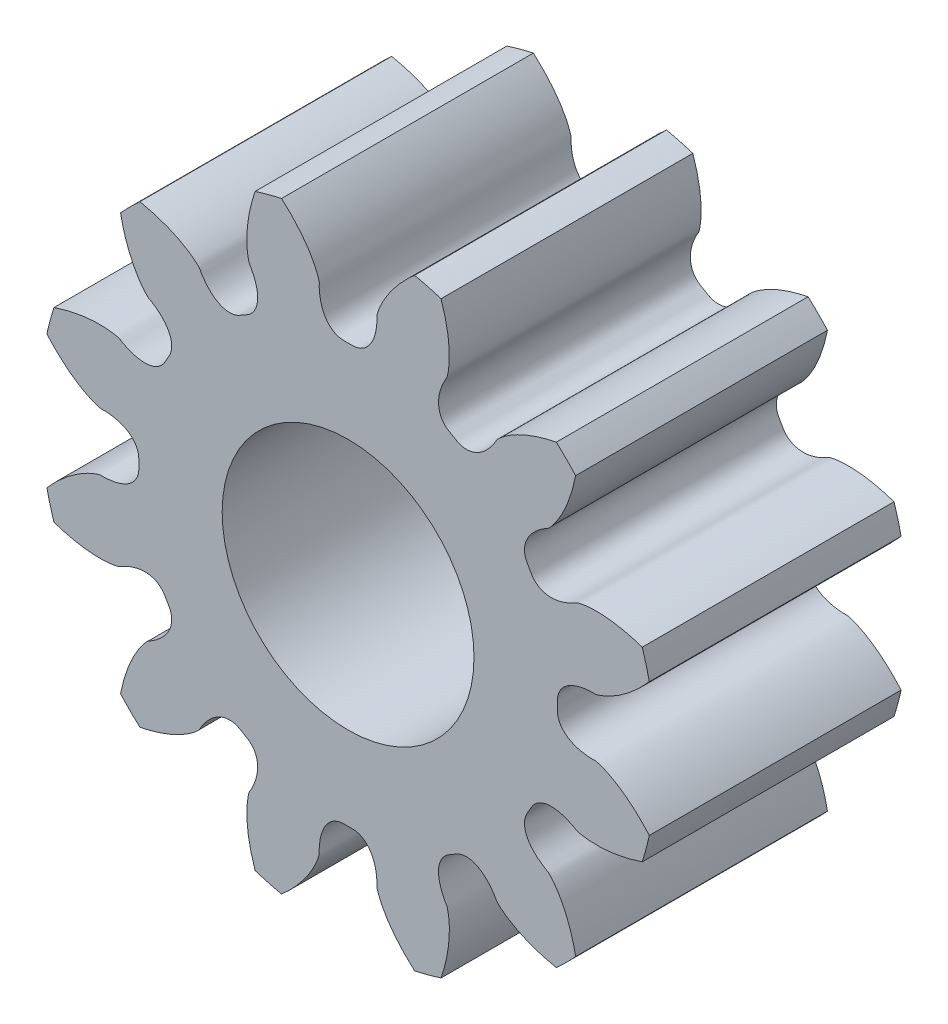
from build123d import *

# Parameters (mm, degrees)
SKETCHREVOLVESPUR01_W       = 6
SKETCHREVOLVESPUR01_H       = 7.34999989
TOOTHEXTRUDECUTSPUR01_DEPTH = 3
PATTERNSPUR01_COUNT         = 12
BOREREVOLVESKETCH_W         = 6
BOREREVOLVESKETCH_H         = 3


with BuildPart() as part:
    # SketchRevolveSpur01 → Spur01 (revolve)
    with BuildSketch(Plane(origin=(0, 0, 0), x_dir=(0, 0, -1), z_dir=(1, 0, 0))):
        with Locations((0, 3.674999945)):
            Rectangle(SKETCHREVOLVESPUR01_W, SKETCHREVOLVESPUR01_H)
    revolve(axis=Axis((0, 0, 0), (0, 0, -1)))

    # SketchToothSpur01 → ToothExtrudeCutSpur01 (cut, symmetric)
    with BuildSketch(Plane.XY):
        with BuildLine():
            ThreePointArc((7.21962798, 1.635229781), (7.402499889, 0), (7.21962798, -1.635229781))
            add(Edge.make_bspline(
                [(7.21962798, -1.635229781), (7.151237937, -1.554717351), (7.047163549, -1.440652032), (6.903909019, -1.30080021), (6.801885859, -1.208412812), (6.702859729, -1.125278452), (6.607372345, -1.051034658), (6.515942174, -0.985291593), (6.429063155, -0.927633008), (6.347203404, -0.877619339), (6.270804388, -0.834782962), (6.200278784, -0.798649498), (6.136012863, -0.768675447), (6.078354848, -0.744450883), (6.027647051, -0.725080192), (5.968370282, -0.705967203), (5.900355358, -0.682103283), (5.825819994, -0.69001413), (5.763383254, -0.68627876), (5.709693969, -0.682747776), (5.657509429, -0.677057875), (5.606780971, -0.669721421), (5.557513548, -0.660611283), (5.50969227, -0.64975072), (5.463302071, -0.637105609), (5.41832401, -0.622633824), (5.37473872, -0.606267172), (5.332529682, -0.587909984), (5.291689026, -0.567432693), (5.252226274, -0.544666559), (5.214181316, -0.519399076), (5.177642887, -0.491372336), (5.142773473, -0.460287485), (5.109840816, -0.425820169), (5.079251858, -0.387653563), (5.05158623, -0.34553511), (5.027595186, -0.299361805), (5.008220993, -0.249278686), (4.994321461, -0.195796435), (4.987974319, -0.145513283), (4.985379301, -0.080025748), (4.989015373, 0), (4.985379301, 0.080025748), (4.987974319, 0.145513283), (4.994321461, 0.195796435), (5.008220993, 0.249278686), (5.027595186, 0.299361805), (5.05158623, 0.34553511), (5.079251858, 0.387653563), (5.109840816, 0.425820169), (5.142773473, 0.460287485), (5.177642887, 0.491372336), (5.214181316, 0.519399076), (5.252226274, 0.544666559), (5.291689026, 0.567432693), (5.332529682, 0.587909984), (5.37473872, 0.606267172), (5.41832401, 0.622633824), (5.463302071, 0.637105609), (5.50969227, 0.64975072), (5.557513548, 0.660611283), (5.606780971, 0.669721421), (5.657509429, 0.677057875), (5.709693969, 0.682747776), (5.763383254, 0.68627876), (5.825819994, 0.69001413), (5.900355358, 0.682103283), (5.968370282, 0.705967203), (6.027647051, 0.725080192), (6.078354848, 0.744450883), (6.136012863, 0.768675447), (6.200278784, 0.798649498), (6.270804388, 0.834782962), (6.347203404, 0.877619339), (6.429063155, 0.927633008), (6.515942174, 0.985291593), (6.607372345, 1.051034658), (6.702859729, 1.125278452), (6.801885859, 1.208412812), (6.903909019, 1.30080021), (7.047163549, 1.440652032), (7.151237937, 1.554717351), (7.21962798, 1.635229781)],
                knots=[0, 0, 0, 0, 0.053494111, 0.078129557, 0.101357264, 0.12317723, 0.143589457, 0.162593944, 0.180190692, 0.1963797, 0.211160968, 0.224534496, 0.236500285, 0.247058334, 0.256208643, 0.263951213, 0.278695042, 0.292012057, 0.301318902, 0.310394671, 0.319249551, 0.327895214, 0.336345061, 0.34461452, 0.352721382, 0.360686187, 0.368532648, 0.376288102, 0.383983955, 0.391656051, 0.399344863, 0.407095315, 0.414955973, 0.42297723, 0.431208054, 0.439690928, 0.448454951, 0.457507871, 0.466828925, 0.476365469, 0.483110202, 0.5, 0.516889798, 0.523634531, 0.533171075, 0.542492129, 0.551545049, 0.560309072, 0.568791946, 0.57702277, 0.585044027, 0.592904685, 0.600655137, 0.608343949, 0.616016045, 0.623711898, 0.631467352, 0.639313813, 0.647278618, 0.65538548, 0.663654939, 0.672104786, 0.680750449, 0.689605329, 0.698681098, 0.707987943, 0.721304958, 0.736048787, 0.743791357, 0.752941666, 0.763499715, 0.775465504, 0.788839032, 0.8036203, 0.819809308, 0.837406056, 0.856410543, 0.87682277, 0.898642736, 0.921870443, 0.946505889, 1, 1, 1, 1], degree=3))
        make_face()
    toothextrudecutspur01 = extrude(amount=TOOTHEXTRUDECUTSPUR01_DEPTH, both=True, mode=Mode.SUBTRACT)

    # PatternSpur01: ToothExtrudeCutSpur01 ×12 about axis
    patternspur01_axis = Axis((0, 0, 50), (0, 0, -1))
    for i in range(1, PATTERNSPUR01_COUNT):
        add(toothextrudecutspur01.rotate(patternspur01_axis, i * 360 / PATTERNSPUR01_COUNT), mode=Mode.SUBTRACT)

    # BoreRevolveSketch → BoreRevolveCut (revolve, cut)
    with BuildSketch(Plane(origin=(0, 0, 0), x_dir=(0, 0, -1), z_dir=(1, 0, 0))):
        with Locations((0, 1.5)):
            Rectangle(BOREREVOLVESKETCH_W, BOREREVOLVESKETCH_H)
    revolve(axis=Axis((0, 0, 0), (0, 0, -1)), mode=Mode.SUBTRACT)


solid = part.part
